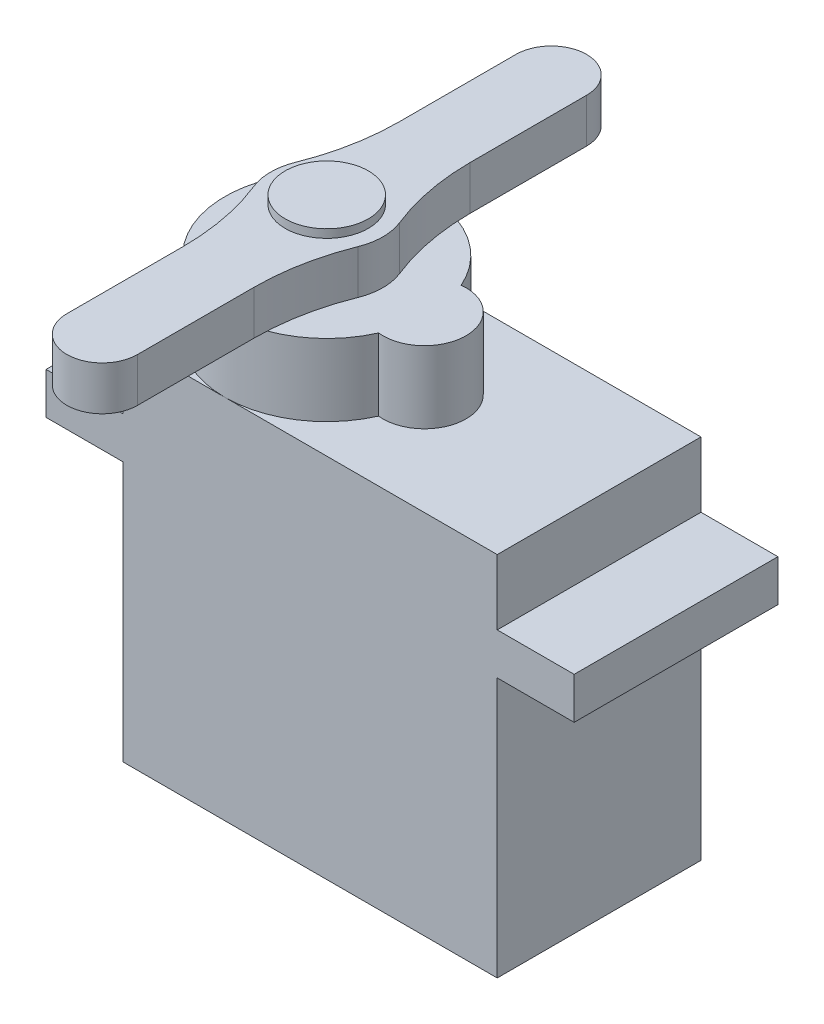
from build123d import *

# Parameters (mm, degrees)
SKETCH1_W           = 22.86
SKETCH1_H           = 12.446
BOSS_EXTRUDE1_DEPTH = 22.4
SKETCH3_W           = 4.699
SKETCH3_H           = 2.54
BOSS_EXTRUDE3_DEPTH = 12.446
BOSS_EXTRUDE4_DEPTH = 4.4
SKETCH5_R           = 2.54
BOSS_EXTRUDE5_DEPTH = 3.2
BOSS_EXTRUDE6_DEPTH = 2.692
BOSS_EXTRUDE7_START = -4.318
SKETCH7_W           = 1.778
SKETCH7_H           = 3.81
BOSS_EXTRUDE7_DEPTH = 1.27


with BuildPart() as part:
    # Sketch1 → Boss-Extrude1 (new body)
    with BuildSketch(Plane(origin=(0, 0, 0), x_dir=(1, 0, 0), z_dir=(0, 1, 0))):
        Rectangle(SKETCH1_W, SKETCH1_H)
    extrude(amount=BOSS_EXTRUDE1_DEPTH)

    # Sketch3 → Boss-Extrude3 (add)
    with BuildSketch(Plane.XY.offset(6.223)):
        with Locations((-13.7795, 17.145)):
            Rectangle(SKETCH3_W, SKETCH3_H)
        with Locations((13.7795, 17.145)):
            Rectangle(SKETCH3_W, SKETCH3_H)
    extrude(amount=-BOSS_EXTRUDE3_DEPTH)

    # Sketch4 → Boss-Extrude4 (add)
    with BuildSketch(Plane(origin=(0, 22.4, 0), x_dir=(1, 0, 0), z_dir=(0, 1, 0))):
        with BuildLine():
            ThreePointArc((0.480978723, 2.524406275), (-11.43, 0), (0.480978723, -2.524406275))
            ThreePointArc((0.480978723, -2.524406275), (3.302, 0), (0.480978723, 2.524406275))
        make_face()
    extrude(amount=BOSS_EXTRUDE4_DEPTH)

    # Sketch5 → Boss-Extrude5 (add)
    with BuildSketch(Plane(origin=(0, 26.8, 0), x_dir=(1, 0, 0), z_dir=(0, 1, 0))):
        with Locations((-5.207, 0)):
            Circle(SKETCH5_R)
    extrude(amount=BOSS_EXTRUDE5_DEPTH)


with BuildPart() as body_2:
    # Sketch6 → Boss-Extrude6 (new body)
    with BuildSketch(Plane(origin=(0, 26.8, 0), x_dir=(1, 0, 0), z_dir=(0, 1, 0))):
        with BuildLine():
            Line((-7.366, 6.604), (-7.366, 13.716))
            ThreePointArc((-7.366, 13.716), (-5.207, 15.875), (-3.048, 13.716))
            Line((-3.048, 13.716), (-3.048, 6.604))
            ThreePointArc((-3.048, 6.604), (-2.789317484, 3.88905433), (-2.022579173, 1.271811698))
            ThreePointArc((-2.022579173, 1.271811698), (-1.778, 0), (-2.022579173, -1.271811698))
            ThreePointArc((-2.022579173, -1.271811698), (-2.789317484, -3.88905433), (-3.048, -6.604))
            Line((-3.048, -6.604), (-3.048, -13.716))
            ThreePointArc((-3.048, -13.716), (-5.207, -15.875), (-7.366, -13.716))
            Line((-7.366, -13.716), (-7.366, -6.604))
            ThreePointArc((-7.366, -6.604), (-7.624682516, -3.88905433), (-8.391420827, -1.271811698))
            ThreePointArc((-8.391420827, -1.271811698), (-8.636, 0), (-8.391420827, 1.271811698))
            ThreePointArc((-8.391420827, 1.271811698), (-7.624682516, 3.88905433), (-7.366, 6.604))
        make_face()
    extrude(amount=BOSS_EXTRUDE6_DEPTH)


with BuildPart() as body_3:
    # Sketch7 → Boss-Extrude7 (new body)
    with BuildSketch(Plane.XZ.offset(BOSS_EXTRUDE7_START)):
        with Locations((-12.319, 0)):
            Rectangle(SKETCH7_W, SKETCH7_H)
    extrude(amount=-BOSS_EXTRUDE7_DEPTH)


solid = Compound([part.part, body_2.part, body_3.part])
